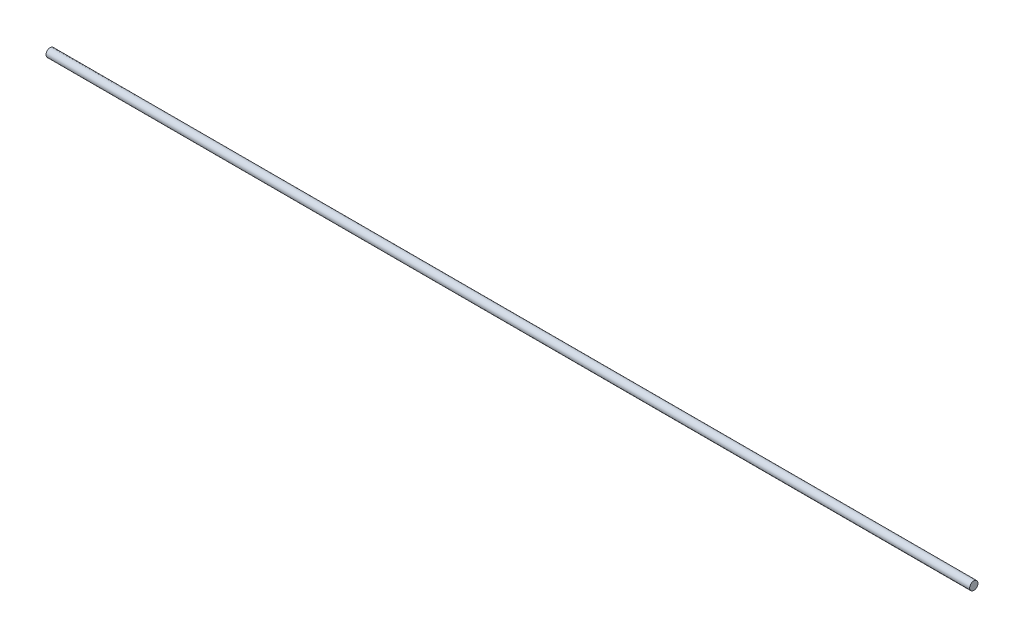
from build123d import *

# Parameters (mm, degrees)
SKETCH12_R          = 0.45
BOSS_EXTRUDE9_DEPTH = 100


with BuildPart() as part:
    # Sketch12 → Boss-Extrude9 (new body)
    with BuildSketch(Plane(origin=(0, 0, 0), x_dir=(0, 0, -1), z_dir=(1, 0, 0))):
        Circle(SKETCH12_R)
    extrude(amount=BOSS_EXTRUDE9_DEPTH)


solid = part.part
